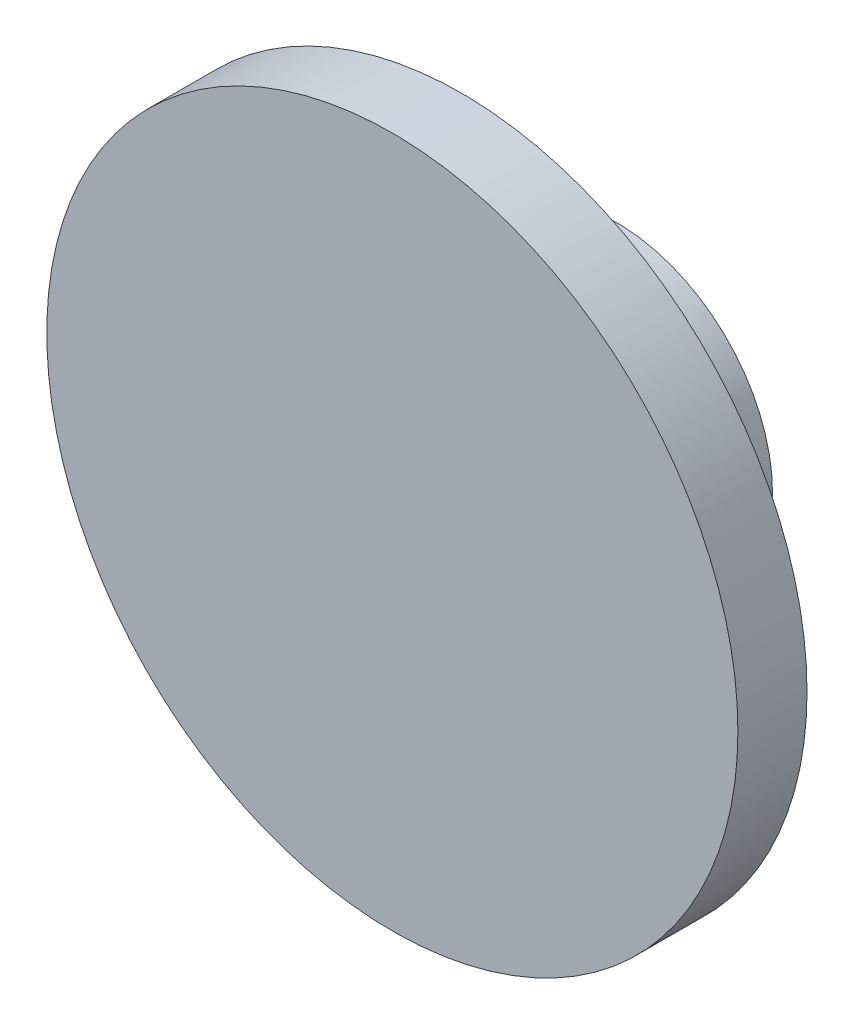
from build123d import *

# Parameters (mm, degrees)
SKETCH1_R           = 4.5
SKETCH1_R_2         = 3.75
BOSS_EXTRUDE1_DEPTH = 4.5
SKETCH2_R           = 10
BOSS_EXTRUDE2_DEPTH = 2


with BuildPart() as part:
    # Sketch1 → Boss-Extrude1 (new body)
    with BuildSketch(Plane.XY):
        Circle(SKETCH1_R)
        Circle(SKETCH1_R_2, mode=Mode.SUBTRACT)
    extrude(amount=BOSS_EXTRUDE1_DEPTH)

    # Sketch2 → Boss-Extrude2 (add)
    with BuildSketch(Plane.XY.offset(4.5)):
        Circle(SKETCH2_R)
    extrude(amount=BOSS_EXTRUDE2_DEPTH)


solid = part.part
